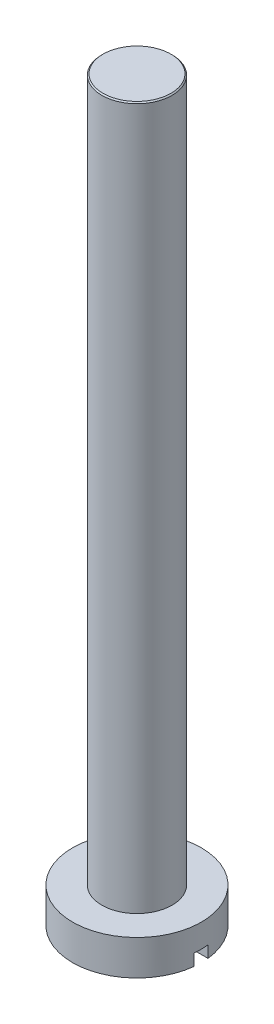
from build123d import *

# Parameters (mm, degrees)
SKETCH1_R           = 1.5
BOSS_EXTRUDE1_DEPTH = 30
SKETCH2_R           = 2.75
BOSS_EXTRUDE2_DEPTH = 1.5
SKETCH3_W           = 8.196351728
SKETCH3_H           = 0.6
CUT_EXTRUDE1_DEPTH  = 0.5
CHAMFER1_SIZE       = 0.05


with BuildPart() as part:
    # Sketch1 → Boss-Extrude1 (new body)
    with BuildSketch(Plane(origin=(0, 0, 0), x_dir=(1, 0, 0), z_dir=(0, 1, 0))):
        Circle(SKETCH1_R)
    extrude(amount=BOSS_EXTRUDE1_DEPTH)

    # Chamfer1
    chamfer1_edges = [part.edges().sort_by_distance(p)[0] for p in [
        (-1.5, 30, 0),
    ]]
    chamfer(chamfer1_edges, length=CHAMFER1_SIZE)


with BuildPart() as body_2:
    # Sketch2 → Boss-Extrude2 (new body)
    with BuildSketch(Plane.XZ):
        Circle(SKETCH2_R)
    extrude(amount=BOSS_EXTRUDE2_DEPTH)

    # Sketch3 → Cut-Extrude1 (cut)
    with BuildSketch(Plane.XZ.offset(1.5)):
        Rectangle(SKETCH3_W, SKETCH3_H)
    extrude(amount=-CUT_EXTRUDE1_DEPTH, mode=Mode.SUBTRACT)


solid = Compound([part.part, body_2.part])
